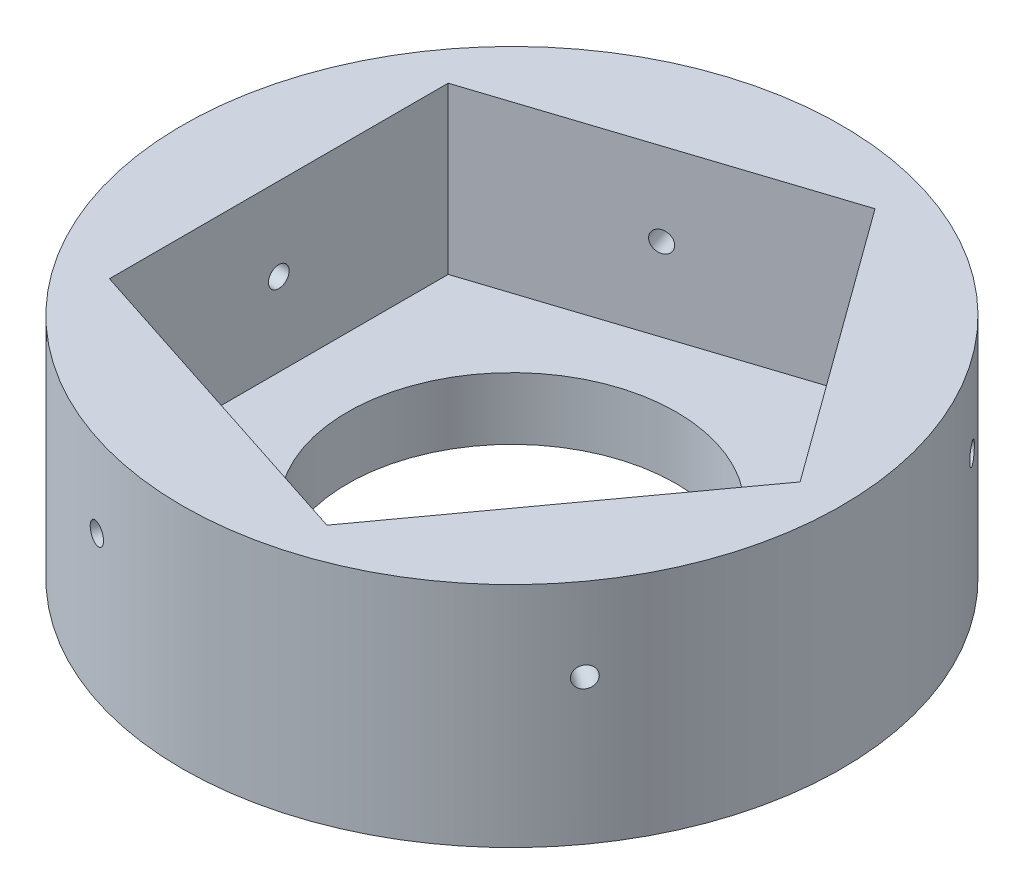
from build123d import *

# Parameters (mm, degrees)
SKETCH1_R                = 69.57983352
SKETCH1_R_2              = 39.6875
BOSS_EXTRUDE1_DEPTH      = 15
SKETCH2_R                = 79.57983352
SKETCH2_R_2              = 69.57983352
BOSS_EXTRUDE2_DEPTH      = 40
BOSS_EXTRUDE2_DEPTH_BACK = 15
BOSS_EXTRUDE3_DEPTH      = 40
SKETCH4_R                = 2.5
CUT_EXTRUDE1_DEPTH       = 44.985172419
CIRPATTERN1_COUNT        = 5


with BuildPart() as part:
    # Sketch1 → Boss-Extrude1 (new body)
    with BuildSketch(Plane(origin=(0, 0, 0), x_dir=(1, 0, 0), z_dir=(0, 1, 0))):
        Circle(SKETCH1_R)
        Circle(SKETCH1_R_2, mode=Mode.SUBTRACT)
    extrude(amount=BOSS_EXTRUDE1_DEPTH)

    # Sketch2 → Boss-Extrude2 (add, two sides)
    with BuildSketch(Plane(origin=(0, 15, 0), x_dir=(1, 0, 0), z_dir=(0, 1, 0))) as boss_extrude2_sk:
        Circle(SKETCH2_R)
        Circle(SKETCH2_R_2, mode=Mode.SUBTRACT)
    extrude(amount=BOSS_EXTRUDE2_DEPTH)
    extrude(boss_extrude2_sk.sketch, amount=-BOSS_EXTRUDE2_DEPTH_BACK)

    # Sketch3 → Boss-Extrude3 (add)
    with BuildSketch(Plane(origin=(0, 15, 0), x_dir=(1, 0, 0), z_dir=(0, 1, 0))):
        with BuildLine():
            ThreePointArc((21.501351023, -66.174354072), (56.291267783, -40.898), (69.57983352, 0))
            Line((69.57983352, 0), (21.501351023, -66.174354072))
        make_face()
        with BuildLine():
            Line((21.501351023, 66.174354072), (69.57983352, 0))
            ThreePointArc((69.57983352, 0), (56.291267783, 40.898), (21.501351023, 66.174354072))
        make_face()
        with BuildLine():
            Line((-56.291267783, 40.898), (21.501351023, 66.174354072))
            ThreePointArc((21.501351023, 66.174354072), (-21.501351023, 66.174354072), (-56.291267783, 40.898))
        make_face()
        with BuildLine():
            ThreePointArc((-56.291267783, -40.898), (-21.501351023, -66.174354072), (21.501351023, -66.174354072))
            Line((21.501351023, -66.174354072), (-56.291267783, -40.898))
        make_face()
        with BuildLine():
            Line((-56.291267783, -40.898), (-56.291267783, 40.898))
            ThreePointArc((-56.291267783, 40.898), (-69.57983352, 0), (-56.291267783, -40.898))
        make_face()
    extrude(amount=BOSS_EXTRUDE3_DEPTH)

    # Sketch4 → Cut-Extrude1 (cut, through all)
    with BuildSketch(Plane(origin=(-17.39495838, 0, -53.536177036), x_dir=(0.951056516, 0, -0.309016994), z_dir=(0.309016994, 0, 0.951056516))):
        with Locations((0, 35)):
            Circle(SKETCH4_R)
    cut_extrude1 = extrude(amount=-CUT_EXTRUDE1_DEPTH, mode=Mode.SUBTRACT)

    # CirPattern1: Cut-Extrude1 ×5 about axis
    cirpattern1_axis = Axis((0, -225.085759711, 0), (0, 1, 0))
    for i in range(1, CIRPATTERN1_COUNT):
        add(cut_extrude1.rotate(cirpattern1_axis, i * 360 / CIRPATTERN1_COUNT), mode=Mode.SUBTRACT)


solid = part.part
